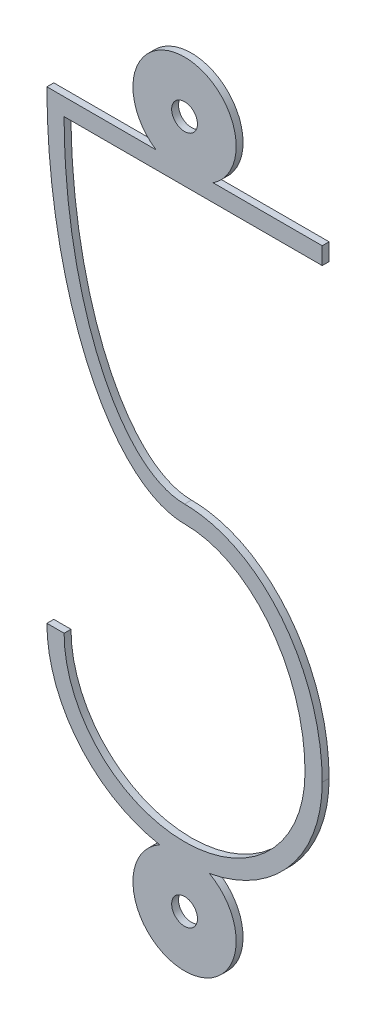
from build123d import *

# Parameters (mm, degrees)
SKETCH1_R           = 0.375
BOSS_EXTRUDE1_DEPTH = 0.1


with BuildPart() as part:
    # Sketch1 → Boss-Extrude1 (new body, symmetric)
    with BuildSketch(Plane.XY):
        with BuildLine():
            Line((-4, -4.75), (-3.5, -4.75))
            ThreePointArc((-3.5, -4.75), (0, -8.25), (3.5, -4.75))
            add(Edge.make_bspline(
                [(3.5, -4.75), (3.5, -0.25), (0, -0.25)],
                knots=[4.71238898, 4.71238898, 4.71238898, 6.283185307, 6.283185307, 6.283185307], degree=2, weights=[1, 0.707106781, 1]))
            add(Edge.make_bspline(
                [(-4, 8.75), (-4, -0.25), (0, -0.25)],
                knots=[4.71238898, 4.71238898, 4.71238898, 6.283185307, 6.283185307, 6.283185307], degree=2, weights=[1, 0.707106781, 1]))
            Line((-4, 8.75), (-0.829156198, 8.75))
            ThreePointArc((-0.829156198, 8.75), (0, 11.5), (0.829156198, 8.75))
            Line((0.829156198, 8.75), (4, 8.75))
            Line((4, 8.75), (4, 8.25))
            Line((4, 8.25), (-3.5, 8.25))
            add(Edge.make_bspline(
                [(-3.5, 8.25), (-3.5, 0.25), (0, 0.25)],
                knots=[1.570796327, 1.570796327, 1.570796327, 3.141592654, 3.141592654, 3.141592654], degree=2, weights=[1, 0.707106781, 1]))
            add(Edge.make_bspline(
                [(4, -4.75), (4, 0.25), (0, 0.25)],
                knots=[4.71238898, 4.71238898, 4.71238898, 6.283185307, 6.283185307, 6.283185307], degree=2, weights=[1, 0.707106781, 1]))
            ThreePointArc((4, -4.75), (3.072711837, -7.310945522), (0.720779018, -8.68452381))
            ThreePointArc((0.720779018, -8.68452381), (0, -11.5), (-0.720779018, -8.68452381))
            ThreePointArc((-0.720779018, -8.68452381), (-3.072711837, -7.310945522), (-4, -4.75))
        make_face()
        with Locations((0, -10)):
            Circle(SKETCH1_R, mode=Mode.SUBTRACT)
        with Locations((0, 10)):
            Circle(SKETCH1_R, mode=Mode.SUBTRACT)
    extrude(amount=BOSS_EXTRUDE1_DEPTH, both=True)


solid = part.part
